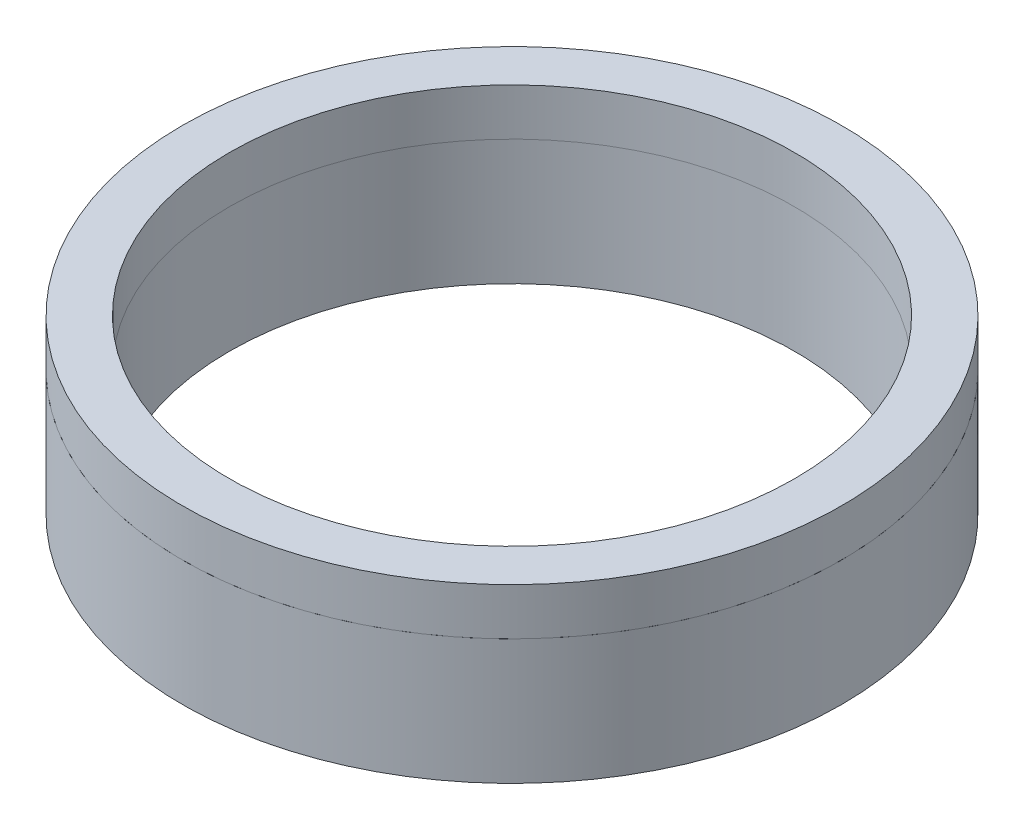
from build123d import *

# Parameters (mm, degrees)
SKETCH1_W           = 3
SKETCH1_H           = 8
SKETCH2_R           = 21.055
SKETCH2_R_2         = 18.055
BOSS_EXTRUDE1_DEPTH = 3


with BuildPart() as part:
    # Sketch1 → Revolve1 (revolve)
    with BuildSketch(Plane.XY):
        with Locations((19.555, 4)):
            Rectangle(SKETCH1_W, SKETCH1_H)
    revolve(axis=Axis((0, 0, 0), (0, 1, 0)))


with BuildPart() as body_2:
    # Sketch2 → Boss-Extrude1 (new body)
    with BuildSketch(Plane(origin=(0, 8, 0), x_dir=(1, 0, 0), z_dir=(0, 1, 0))):
        Circle(SKETCH2_R)
        Circle(SKETCH2_R_2, mode=Mode.SUBTRACT)
    extrude(amount=BOSS_EXTRUDE1_DEPTH)


solid = Compound([part.part, body_2.part])
